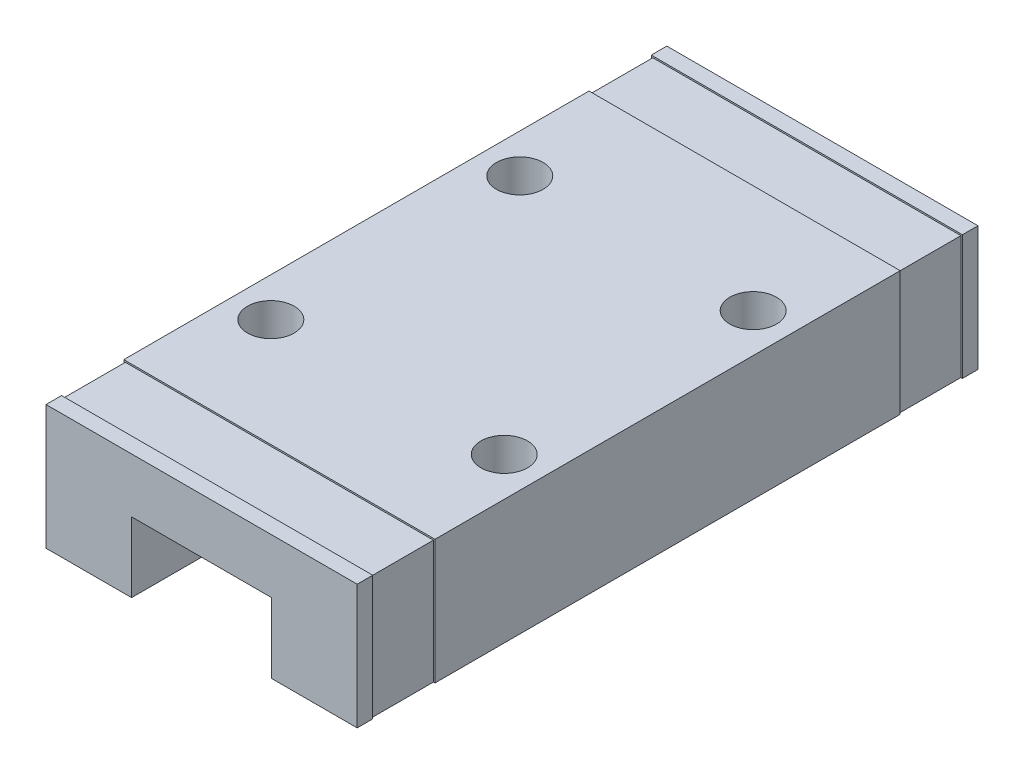
from build123d import *

# Parameters (mm, degrees)
BOSS_EXTRUDE1_DEPTH = 39.9
SKETCH2_W           = 20
SKETCH2_H           = 4
CUT_EXTRUDE1_DEPTH  = 0.1
SKETCH3_W           = 4
SKETCH3_H           = 7.9
CUT_EXTRUDE2_DEPTH  = 0.1
SKETCH4_W           = 4
SKETCH4_H           = 7.9
CUT_EXTRUDE3_DEPTH  = 0.1
SKETCH5_R           = 1.5
CUT_EXTRUDE4_DEPTH  = 3


with BuildPart() as part:
    # Sketch1 → Boss-Extrude1 (new body)
    with BuildSketch(Plane.XY):
        Polygon((14.5, 0), (14.5, 4.5), (5.5, 4.5), (5.5, 0), (0, 0), (0, 8), (20, 8), (20, 0), align=None)
    extrude(amount=BOSS_EXTRUDE1_DEPTH)

    # Sketch2 → Cut-Extrude1 (cut)
    with BuildSketch(Plane(origin=(0, 8, 0), x_dir=(1, 0, 0), z_dir=(0, 1, 0))):
        with Locations((10, -3)):
            Rectangle(SKETCH2_W, SKETCH2_H)
        with Locations((10, -36.9)):
            Rectangle(SKETCH2_W, SKETCH2_H)
    extrude(amount=-CUT_EXTRUDE1_DEPTH, mode=Mode.SUBTRACT)

    # Sketch3 → Cut-Extrude2 (cut)
    with BuildSketch(Plane.ZY):
        with Locations((3, 3.95)):
            Rectangle(SKETCH3_W, SKETCH3_H)
        with Locations((36.9, 3.95)):
            Rectangle(SKETCH3_W, SKETCH3_H)
    extrude(amount=-CUT_EXTRUDE2_DEPTH, mode=Mode.SUBTRACT)

    # Sketch4 → Cut-Extrude3 (cut)
    with BuildSketch(Plane(origin=(20, 0, 0), x_dir=(0, 0, -1), z_dir=(1, 0, 0))):
        with Locations((-36.9, 3.95)):
            Rectangle(SKETCH4_W, SKETCH4_H)
        with Locations((-3, 3.95)):
            Rectangle(SKETCH4_W, SKETCH4_H)
    extrude(amount=-CUT_EXTRUDE3_DEPTH, mode=Mode.SUBTRACT)

    # Sketch5 → Cut-Extrude4 (cut)
    with BuildSketch(Plane(origin=(0, 8, 0), x_dir=(1, 0, 0), z_dir=(0, 1, 0))):
        with Locations((2.5, -11.95)):
            Circle(SKETCH5_R)
        with Locations((17.5, -11.95)):
            Circle(SKETCH5_R)
        with Locations((2.5, -27.95)):
            Circle(SKETCH5_R)
        with Locations((17.5, -27.95)):
            Circle(SKETCH5_R)
    extrude(amount=-CUT_EXTRUDE4_DEPTH, mode=Mode.SUBTRACT)


solid = part.part
